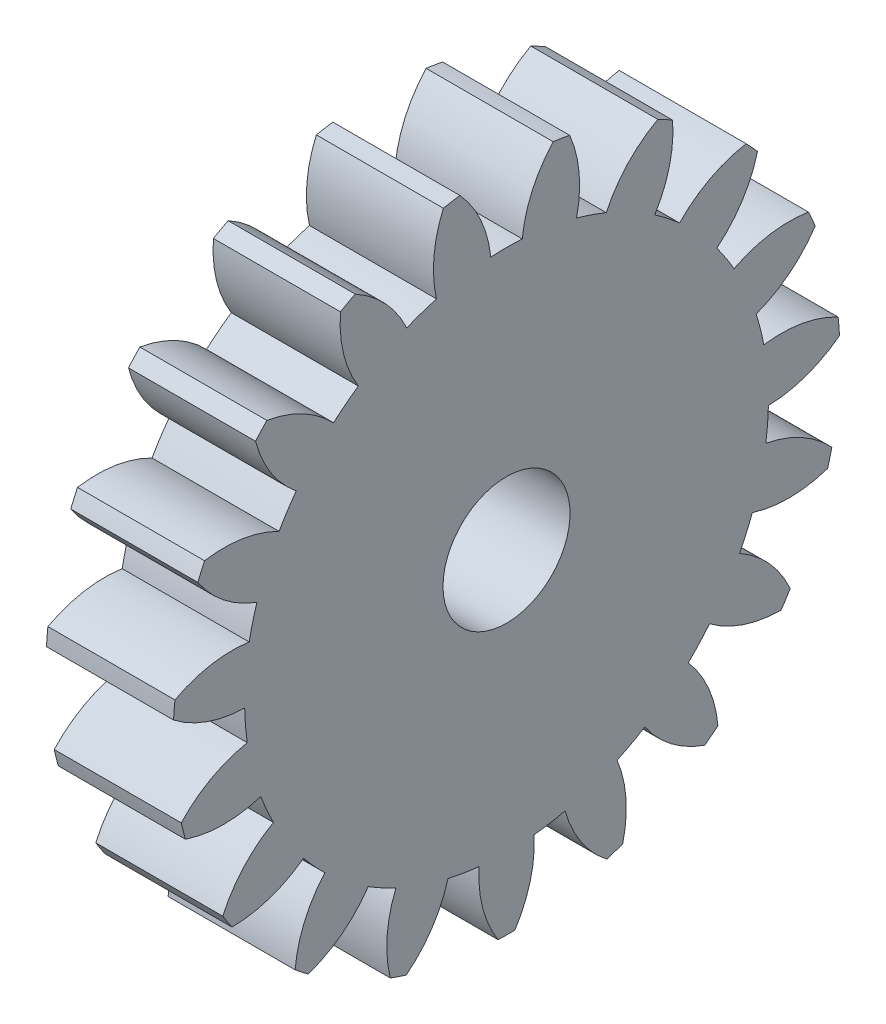
from build123d import *

# Parameters (mm, degrees)
BASPROSKE_W     = 1
BASPROSKE_H     = 2.625
TOOTHCUT_DEPTH  = 4.844639125
TEETHCUTS_COUNT = 19
TEETHCUTS_ANGLE = 341.052631579
BORSKE_R        = 0.5
BORE_DEPTH      = 50.0000508


with BuildPart() as part:
    # BasProSke → Base-Revolve (revolve)
    with BuildSketch(Plane(origin=(0, 0, 0), x_dir=(1, 0, 0), z_dir=(0, 1, 0)), mode=Mode.PRIVATE) as base_revolve_sk:
        with Locations((0.5, 1.3125)):
            Rectangle(BASPROSKE_W, BASPROSKE_H)
    revolve(base_revolve_sk.sketch.rotate(Axis((-10, 0, 0), (1, 0, 0)), 180), axis=Axis((-10, 0, 0), (1, 0, 0)))

    # TooCutSke → ToothCut (cut, through all)
    with BuildSketch(Plane(origin=(0, 0, 0), x_dir=(0, 0, -1), z_dir=(1, 0, 0))):
        with BuildLine():
            ThreePointArc((0.123896259, 2.057773546), (0, 2.0615), (-0.123896259, 2.057773546))
            ThreePointArc((-0.123896259, 2.057773546), (-0.208415718, 2.362069038), (-0.388016755, 2.621843466))
            ThreePointArc((-0.388016755, 2.621843466), (0, 2.6504), (0.388016755, 2.621843466))
            ThreePointArc((0.388016755, 2.621843466), (0.208415718, 2.362069038), (0.123896259, 2.057773546))
        make_face()
    toothcut = extrude(amount=TOOTHCUT_DEPTH, mode=Mode.SUBTRACT)

    # TeethCuts: ToothCut ×19 about axis
    teethcuts_axis = Axis((-10, 0, 0), (1, 0, 0))
    for i in range(1, TEETHCUTS_COUNT):
        add(toothcut.rotate(teethcuts_axis, i * TEETHCUTS_ANGLE / (TEETHCUTS_COUNT - 1)), mode=Mode.SUBTRACT)

    # BorSke → Bore (cut, symmetric)
    with BuildSketch(Plane(origin=(0, 0, 0), x_dir=(0, 0, -1), z_dir=(1, 0, 0))):
        with Locations(Location((0, 0, 0), (0, 0, 180))):
            Circle(BORSKE_R)
    extrude(amount=BORE_DEPTH, both=True, mode=Mode.SUBTRACT)


solid = part.part
